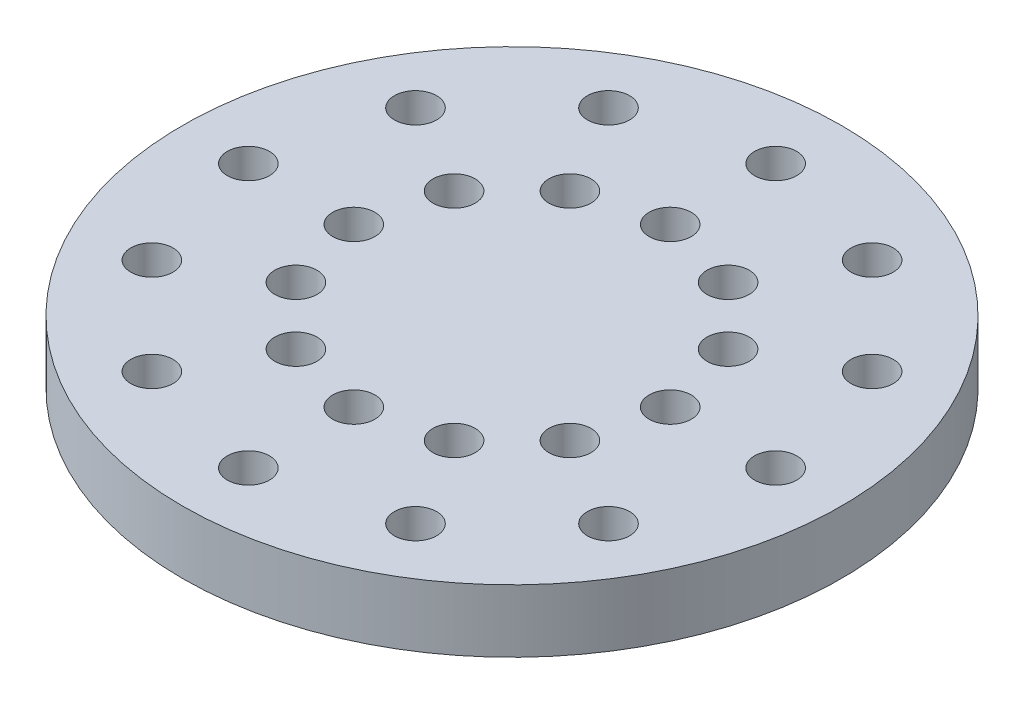
from build123d import *

# Parameters (mm, degrees)
SKETCH1_R           = 25
SKETCH1_R_2         = 1.6
BOSS_EXTRUDE1_DEPTH = 4.7625


with BuildPart() as part:
    # Sketch1 → Boss-Extrude1 (new body)
    with BuildSketch(Plane(origin=(0, 0, 0), x_dir=(1, 0, 0), z_dir=(0, 1, 0))):
        Circle(SKETCH1_R)
        with Locations((20, 0)):
            Circle(SKETCH1_R_2, mode=Mode.SUBTRACT)
        with Locations((12, 0)):
            Circle(SKETCH1_R_2, mode=Mode.SUBTRACT)
        with Locations((17.320508076, -10)):
            Circle(SKETCH1_R_2, mode=Mode.SUBTRACT)
        with Locations((10.392304845, -6)):
            Circle(SKETCH1_R_2, mode=Mode.SUBTRACT)
        with Locations((10, -17.320508076)):
            Circle(SKETCH1_R_2, mode=Mode.SUBTRACT)
        with Locations((6, -10.392304845)):
            Circle(SKETCH1_R_2, mode=Mode.SUBTRACT)
        with Locations((0, -20)):
            Circle(SKETCH1_R_2, mode=Mode.SUBTRACT)
        with Locations((0, -12)):
            Circle(SKETCH1_R_2, mode=Mode.SUBTRACT)
        with Locations((-10, -17.320508076)):
            Circle(SKETCH1_R_2, mode=Mode.SUBTRACT)
        with Locations((-6, -10.392304845)):
            Circle(SKETCH1_R_2, mode=Mode.SUBTRACT)
        with Locations((-17.320508076, -10)):
            Circle(SKETCH1_R_2, mode=Mode.SUBTRACT)
        with Locations((-10.392304845, -6)):
            Circle(SKETCH1_R_2, mode=Mode.SUBTRACT)
        with Locations((-20, 0)):
            Circle(SKETCH1_R_2, mode=Mode.SUBTRACT)
        with Locations((-12, 0)):
            Circle(SKETCH1_R_2, mode=Mode.SUBTRACT)
        with Locations((-17.320508076, 10)):
            Circle(SKETCH1_R_2, mode=Mode.SUBTRACT)
        with Locations((-10.392304845, 6)):
            Circle(SKETCH1_R_2, mode=Mode.SUBTRACT)
        with Locations((-10, 17.320508076)):
            Circle(SKETCH1_R_2, mode=Mode.SUBTRACT)
        with Locations((-6, 10.392304845)):
            Circle(SKETCH1_R_2, mode=Mode.SUBTRACT)
        with Locations((0, 20)):
            Circle(SKETCH1_R_2, mode=Mode.SUBTRACT)
        with Locations((0, 12)):
            Circle(SKETCH1_R_2, mode=Mode.SUBTRACT)
        with Locations((10, 17.320508076)):
            Circle(SKETCH1_R_2, mode=Mode.SUBTRACT)
        with Locations((6, 10.392304845)):
            Circle(SKETCH1_R_2, mode=Mode.SUBTRACT)
        with Locations((17.320508076, 10)):
            Circle(SKETCH1_R_2, mode=Mode.SUBTRACT)
        with Locations((10.392304845, 6)):
            Circle(SKETCH1_R_2, mode=Mode.SUBTRACT)
    extrude(amount=BOSS_EXTRUDE1_DEPTH)


solid = part.part
